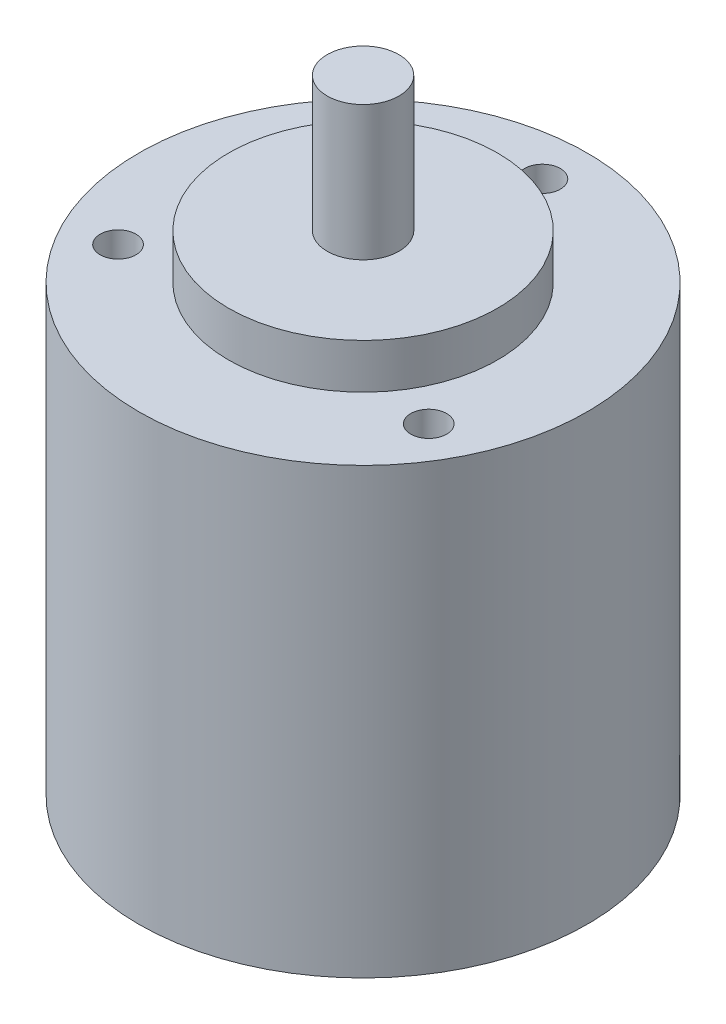
from build123d import *

# Parameters (mm, degrees)
SKETCH1_R           = 25
BOSS_EXTRUDE1_DEPTH = 49.5
SKETCH2_R           = 15
BOSS_EXTRUDE2_DEPTH = 5
SKETCH3_R           = 4
BOSS_EXTRUDE3_DEPTH = 15
SKETCH4_R           = 2
CUT_EXTRUDE1_DEPTH  = 10


with BuildPart() as part:
    # Sketch1 → Boss-Extrude1 (new body)
    with BuildSketch(Plane(origin=(0, 0, 0), x_dir=(1, 0, 0), z_dir=(0, 1, 0))):
        Circle(SKETCH1_R)
    extrude(amount=BOSS_EXTRUDE1_DEPTH)

    # Sketch2 → Boss-Extrude2 (add)
    with BuildSketch(Plane(origin=(0, 49.5, 0), x_dir=(1, 0, 0), z_dir=(0, 1, 0))):
        Circle(SKETCH2_R)
    extrude(amount=BOSS_EXTRUDE2_DEPTH)

    # Sketch3 → Boss-Extrude3 (add)
    with BuildSketch(Plane(origin=(0, 54.5, 0), x_dir=(1, 0, 0), z_dir=(0, 1, 0))):
        Circle(SKETCH3_R)
    extrude(amount=BOSS_EXTRUDE3_DEPTH)

    # Sketch4 → Cut-Extrude1 (cut)
    with BuildSketch(Plane(origin=(0, 49.5, 0), x_dir=(1, 0, 0), z_dir=(0, 1, 0))):
        with Locations((0, 20)):
            Circle(SKETCH4_R)
        with Locations((17.320508076, -10)):
            Circle(SKETCH4_R)
        with Locations((-17.320508076, -10)):
            Circle(SKETCH4_R)
    extrude(amount=-CUT_EXTRUDE1_DEPTH, mode=Mode.SUBTRACT)


solid = part.part
